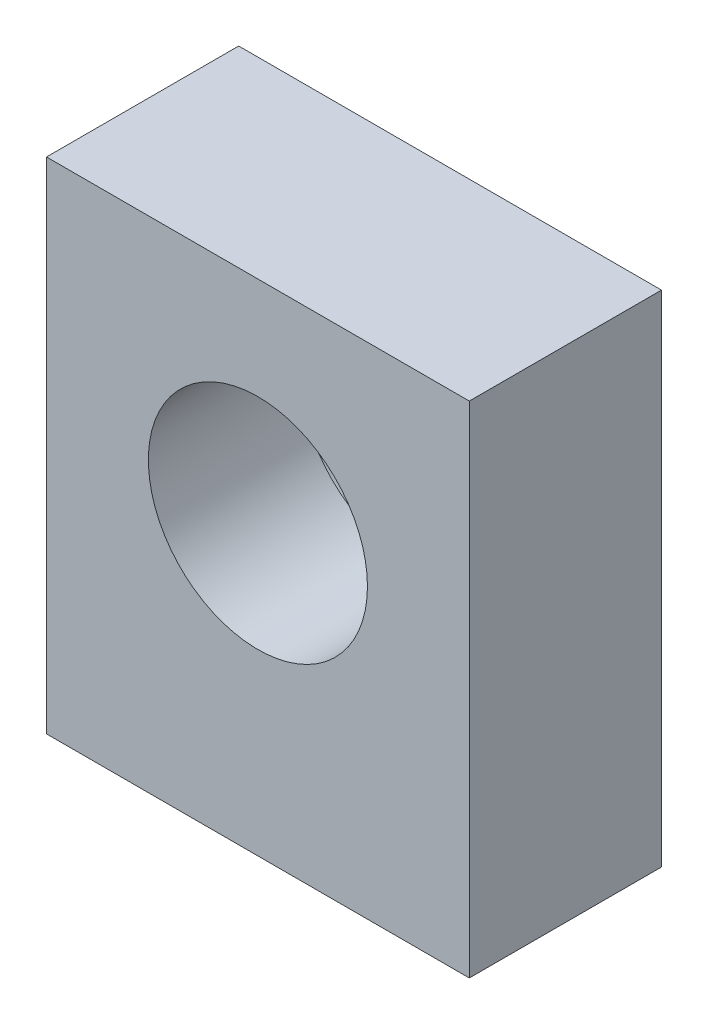
from build123d import *

# Parameters (mm, degrees)
SKETCH1_W                       = 22
SKETCH1_H                       = 10
BOSS_EXTRUDE1_DEPTH             = 26
SKETCH7_R                       = 5.7
CUT_EXTRUDE1_DEPTH              = 11
SKETCH9_R                       = 8.05
CUT_EXTRUDE3_DEPTH              = 2.1
M3X0_5_TAPPED_HOLE1_D           = 2.5
M3X0_5_TAPPED_HOLE1_DEPTH       = 5
M3X0_5_TAPPED_HOLE1_CSINK_D     = 3.05
M3X0_5_TAPPED_HOLE1_CSINK_ANGLE = 90
M3X0_5_TAPPED_HOLE1_TIP         = 0.751075774


with BuildPart() as part:
    # Sketch1 → Boss-Extrude1 (new body)
    with BuildSketch(Plane(origin=(0, 0, 0), x_dir=(1, 0, 0), z_dir=(0, 1, 0))):
        with Locations((11, 5)):
            Rectangle(SKETCH1_W, SKETCH1_H)
    extrude(amount=BOSS_EXTRUDE1_DEPTH)

    # Sketch7 → Cut-Extrude1 (cut, through all)
    with BuildSketch(Plane.XY):
        with Locations((11, 15)):
            Circle(SKETCH7_R)
    extrude(amount=-CUT_EXTRUDE1_DEPTH, mode=Mode.SUBTRACT)

    # Sketch9 → Cut-Extrude3 (cut)
    with BuildSketch(Plane(origin=(0, 0, -10), x_dir=(-1, 0, 0), z_dir=(0, 0, -1))):
        with Locations((-11, 15)):
            Circle(SKETCH9_R)
    extrude(amount=-CUT_EXTRUDE3_DEPTH, mode=Mode.SUBTRACT)

    # M3x0.5 Tapped Hole1
    with Locations(Plane(origin=(0, 0, 0), x_dir=(-1, 0, 0), z_dir=(0, -1, 0))):
        with Locations((-3, 3), (-19, 3), (-11, 7)):
            CounterSinkHole(M3X0_5_TAPPED_HOLE1_D / 2, M3X0_5_TAPPED_HOLE1_CSINK_D / 2, depth=M3X0_5_TAPPED_HOLE1_DEPTH, counter_sink_angle=M3X0_5_TAPPED_HOLE1_CSINK_ANGLE)
            with Locations((0, 0, -(M3X0_5_TAPPED_HOLE1_DEPTH + M3X0_5_TAPPED_HOLE1_TIP / 2))):  # 118° drill point
                Cone(0, M3X0_5_TAPPED_HOLE1_D / 2, M3X0_5_TAPPED_HOLE1_TIP, mode=Mode.SUBTRACT)


solid = part.part
